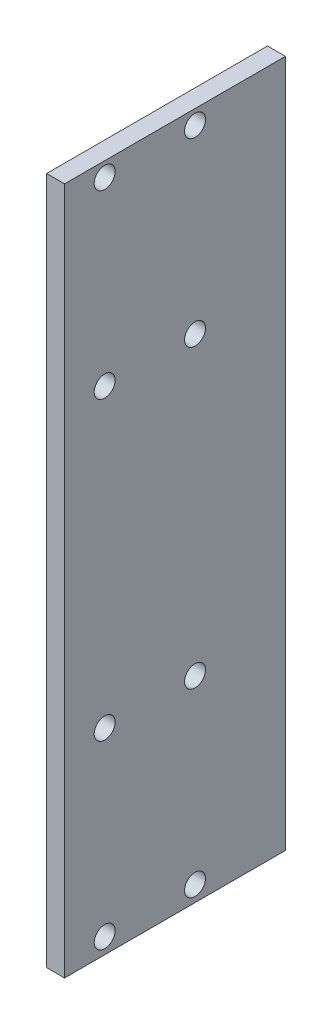
from build123d import *

# Parameters (mm, degrees)
SKETCH1_W           = 39.1132
SKETCH1_H           = 121.796
SKETCH1_R           = 1.8542
BOSS_EXTRUDE1_DEPTH = 3.175


with BuildPart() as part:
    # Sketch1 → Boss-Extrude1 (new body)
    with BuildSketch(Plane(origin=(0, 0, 0), x_dir=(0, 0, -1), z_dir=(1, 0, 0))):
        with Locations((-62.4434, 42.102)):
            Rectangle(SKETCH1_W, SKETCH1_H)
        with Locations((-74.8898, -16.000000004)):
            Circle(SKETCH1_R, mode=Mode.SUBTRACT)
        with Locations((-58.8898, -16.000000004)):
            Circle(SKETCH1_R, mode=Mode.SUBTRACT)
        with Locations((-74.8898, 16.000000004)):
            Circle(SKETCH1_R, mode=Mode.SUBTRACT)
        with Locations((-58.8898, 16.000000004)):
            Circle(SKETCH1_R, mode=Mode.SUBTRACT)
        with Locations((-74.8898, 100.431124449)):
            Circle(SKETCH1_R, mode=Mode.SUBTRACT)
        with Locations((-58.8898, 100.431124449)):
            Circle(SKETCH1_R, mode=Mode.SUBTRACT)
        with Locations((-74.8898, 68.431124441)):
            Circle(SKETCH1_R, mode=Mode.SUBTRACT)
        with Locations((-58.8898, 68.431124441)):
            Circle(SKETCH1_R, mode=Mode.SUBTRACT)
    extrude(amount=BOSS_EXTRUDE1_DEPTH)


solid = part.part
